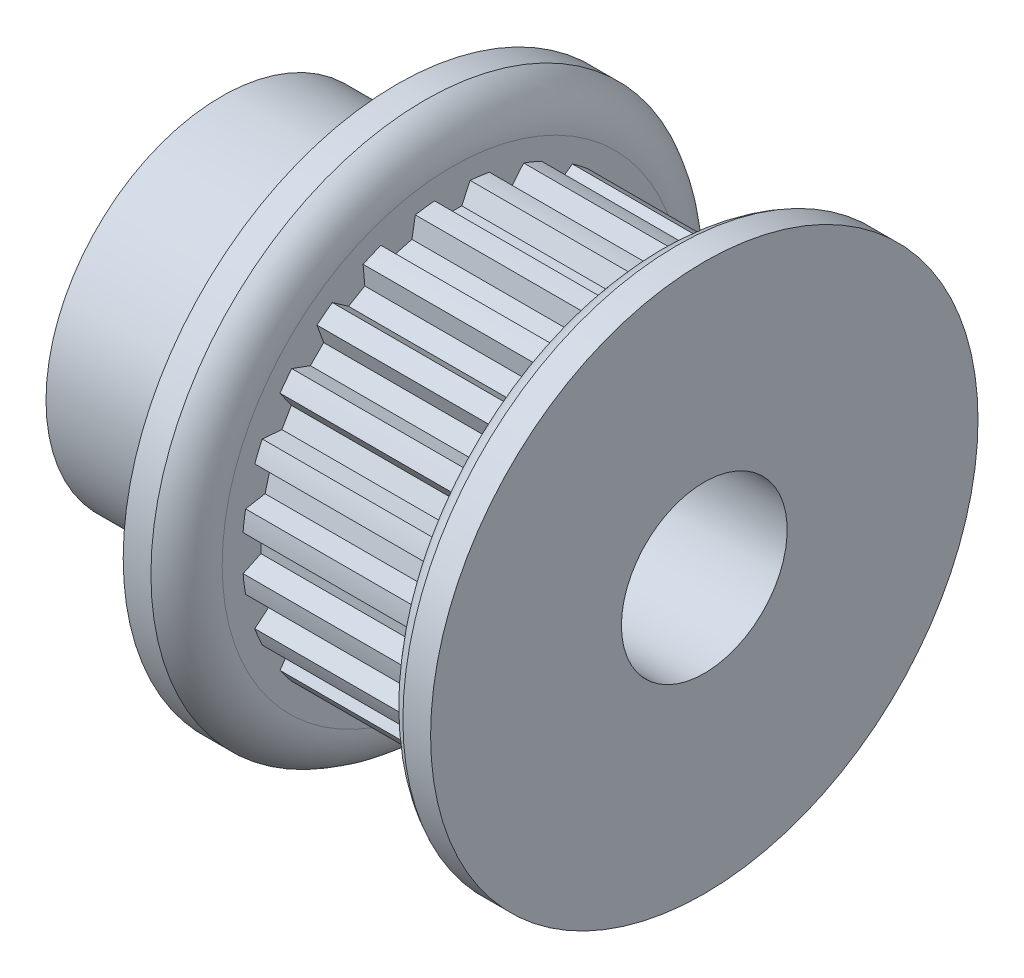
from build123d import *

# Parameters (mm, degrees)
SKETCH4_R          = 7.7597
SKETCH4_R_2        = 7.60095
CUT_EXTRUDE2_DEPTH = 7.112
CUT_EXTRUDE1_DEPTH = 7.112
CIRPATTERN1_COUNT  = 24
SKETCH6_R          = 3
CUT_EXTRUDE3_DEPTH = 23.397327676


with BuildPart() as part:
    # Sketch1 → Revolve1 (revolve)
    with BuildSketch(Plane.XY, mode=Mode.PRIVATE) as revolve1_sk:
        with BuildLine():
            Line((-8.7376, 2.38125), (8.7376, 2.38125))
            Line((8.7376, 2.38125), (8.7376, 9.906))
            Line((8.7376, 9.906), (7.7343, 9.906))
            ThreePointArc((7.7343, 9.906), (7.003135774, 9.264822773), (6.731, 8.3312))
            Line((6.731, 8.3312), (6.731, 7.7597))
            Line((6.731, 7.7597), (-0.381, 7.7597))
            Line((-0.381, 7.7597), (-0.381, 8.3312))
            ThreePointArc((-0.381, 8.3312), (-0.653135774, 9.264822773), (-1.3843, 9.906))
            Line((-1.3843, 9.906), (-2.3876, 9.906))
            Line((-2.3876, 9.906), (-2.3876, 6.35))
            Line((-2.3876, 6.35), (-8.7376, 6.35))
            Line((-8.7376, 6.35), (-8.7376, 2.38125))
        make_face()
    revolve(revolve1_sk.sketch.rotate(Axis((-8.7376, 0, 0), (1, 0, 0)), 90), axis=Axis((-8.7376, 0, 0), (1, 0, 0)))

    # Sketch4 → Cut-Extrude2 (cut)
    with BuildSketch(Plane(origin=(-0.381, 0, 0), x_dir=(0, 0, -1), z_dir=(1, 0, 0))):
        Circle(SKETCH4_R)
        with Locations(Location((0, 0, 0), (0, 0, 180))):
            Circle(SKETCH4_R_2, mode=Mode.SUBTRACT)
    extrude(amount=CUT_EXTRUDE2_DEPTH, mode=Mode.SUBTRACT)

    # Sketch3 → Cut-Extrude1 (cut)
    with BuildSketch(Plane(origin=(-0.381, 0, 0), x_dir=(0, 0, -1), z_dir=(1, 0, 0))):
        with BuildLine():
            Line((-0.643066132, 7.57369836), (-0.340952079, 6.925812683))
            Line((-0.340952079, 6.925812683), (0.340952079, 6.925812683))
            Line((0.340952079, 6.925812683), (0.643066132, 7.57369836))
            ThreePointArc((0.643066132, 7.57369836), (0, 7.60095), (-0.643066132, 7.57369836))
        make_face()
    cut_extrude1 = extrude(amount=CUT_EXTRUDE1_DEPTH, mode=Mode.SUBTRACT)

    # CirPattern1: Cut-Extrude1 ×24 about axis
    cirpattern1_axis = Axis((0, 0, 0), (1, 0, 0))
    for i in range(1, CIRPATTERN1_COUNT):
        add(cut_extrude1.rotate(cirpattern1_axis, i * 360 / CIRPATTERN1_COUNT), mode=Mode.SUBTRACT)

    # Sketch6 → Cut-Extrude3 (cut, through all)
    with BuildSketch(Plane.ZY.offset(8.7376)):
        Circle(SKETCH6_R)
    extrude(amount=-CUT_EXTRUDE3_DEPTH, mode=Mode.SUBTRACT)


solid = part.part
